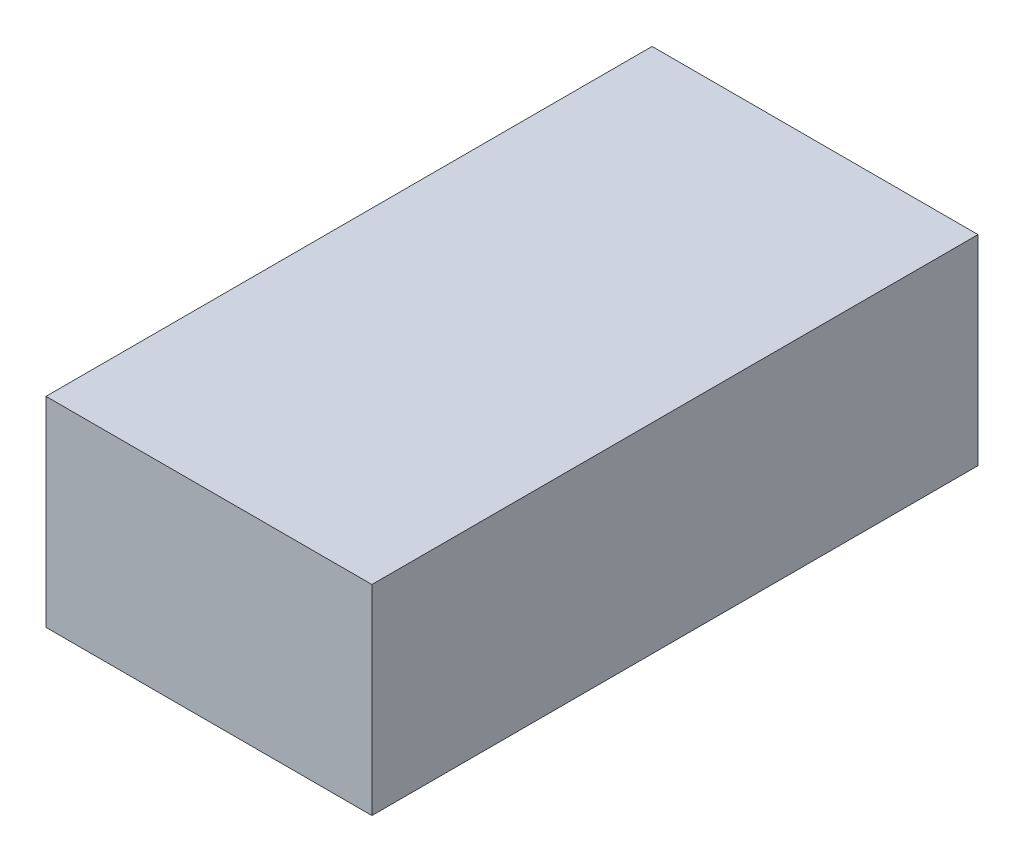
from build123d import *

# Parameters (mm, degrees)
SKETCH1_W           = 57
SKETCH1_H           = 106
BOSS_EXTRUDE1_DEPTH = 35


with BuildPart() as part:
    # Sketch1 → Boss-Extrude1 (new body)
    with BuildSketch(Plane(origin=(0, 0, 0), x_dir=(1, 0, 0), z_dir=(0, 1, 0))):
        with Locations((-28.5, -53)):
            Rectangle(SKETCH1_W, SKETCH1_H)
    extrude(amount=BOSS_EXTRUDE1_DEPTH)


solid = part.part
